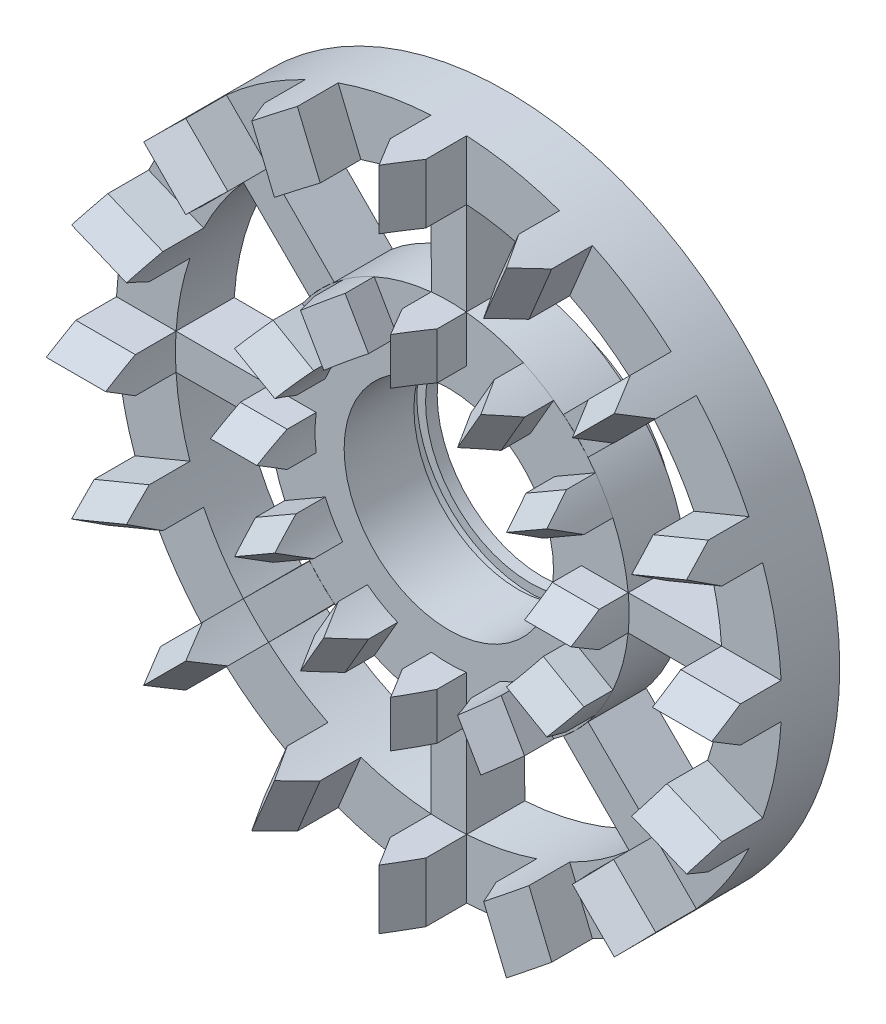
from build123d import *

# Parameters (mm, degrees)
EXTRUDE_1_DEPTH          = 6
SKETCH_4_R               = 28.608695652
SKETCH_4_R_2             = 23.5
EXTRUDE_2_DEPTH          = 5
CUT_EXTRUDE_1_DEPTH      = 6
PATTERN_CIRCULAR_1_COUNT = 16
EXTRUDE_3_DEPTH          = 5
CUT_EXTRUDE_2_DEPTH      = 5
PATTERN_CIRCULAR_7_COUNT = 12
SKETCH_8_R               = 15.48938983
SKETCH_8_R_2             = 11.5
EXTRUDE_4_DEPTH          = 5
EXTRUDE_5_DEPTH          = 5
SKETCH_10_R              = 11.5
SKETCH_10_R_2            = 9
EXTRUDE_6_DEPTH          = 8
SKETCH_11_W              = 1
SKETCH_11_H              = 0.75


with BuildPart() as part:
    # 草图1 → 凸台-拉伸1 (new body)
    with BuildSketch(Plane.XY):
        with BuildLine():
            Line((1.532608696, 23.449970375), (1.532608696, 28.567614137))
            ThreePointArc((1.532608696, 28.567614137), (0, 28.608695652), (-1.532608696, 28.567614137))
            Line((-1.532608696, 28.567614137), (-1.532608696, 23.449970375))
            ThreePointArc((-1.532608696, 23.449970375), (0, 23.5), (1.532608696, 23.449970375))
        make_face()
    extrude_1 = extrude(amount=EXTRUDE_1_DEPTH)

    # 草图4 → 凸台-拉伸2 (add)
    with BuildSketch(Plane.XY):
        Circle(SKETCH_4_R)
        Circle(SKETCH_4_R_2, mode=Mode.SUBTRACT)
    extrude(amount=-EXTRUDE_2_DEPTH)

    # 草图5 → 切除-拉伸1 (cut)
    with BuildSketch(Plane(origin=(0, 23, 0), x_dir=(1, 0, 0), z_dir=(0, 1, 0))):
        Polygon((0, -6), (-1.532608696, -3.5), (-1.532608696, -6), align=None)
        Polygon((1.532608696, -3.5), (0, -6), (1.532608696, -6), align=None)
    cut_extrude_1 = extrude(amount=CUT_EXTRUDE_1_DEPTH, mode=Mode.SUBTRACT)

    # 阵列(圆周)1: 凸台-拉伸1, 切除-拉伸1 ×16 about axis
    pattern_circular_1_axis = Axis((0, 0, 0), (0, 0, 1))
    for i in range(1, PATTERN_CIRCULAR_1_COUNT):
        add(extrude_1.rotate(pattern_circular_1_axis, i * 360 / PATTERN_CIRCULAR_1_COUNT))
        add(cut_extrude_1.rotate(pattern_circular_1_axis, i * 360 / PATTERN_CIRCULAR_1_COUNT), mode=Mode.SUBTRACT)

    # 草图9 → 凸台-拉伸5 (add)
    with BuildSketch(Plane.XY):
        with BuildLine():
            ThreePointArc((1.532608696, 23.449970375), (0, 23.5), (-1.532608696, 23.449970375))
            Line((-1.532608696, 23.449970375), (-1.500043254, 15.427244415))
            ThreePointArc((-1.500043254, 15.427244415), (-2.1729e-05, 15.5), (1.5, 15.427248621))
            Line((1.5, 15.427248621), (1.532608696, 23.449970375))
        make_face()
        with BuildLine():
            ThreePointArc((17.665351072, 15.497915069), (16.617009358, 16.617009358), (15.497915069, 17.665351072))
            Line((15.497915069, 17.665351072), (9.848018383, 11.969399898))
            ThreePointArc((9.848018383, 11.969399898), (10.960139744, 10.960170473), (11.969372286, 9.848051943))
            Line((11.969372286, 9.848051943), (17.665351072, 15.497915069))
        make_face()
        with BuildLine():
            ThreePointArc((23.449970375, -1.532608696), (23.5, 0), (23.449970375, 1.532608696))
            Line((23.449970375, 1.532608696), (15.427244415, 1.500043254))
            ThreePointArc((15.427244415, 1.500043254), (15.5, 2.1729e-05), (15.427248621, -1.5))
            Line((15.427248621, -1.5), (23.449970375, -1.532608696))
        make_face()
        with BuildLine():
            ThreePointArc((15.497915069, -17.665351072), (16.617009358, -16.617009358), (17.665351072, -15.497915069))
            Line((17.665351072, -15.497915069), (11.969399898, -9.848018383))
            ThreePointArc((11.969399898, -9.848018383), (10.960170473, -10.960139744), (9.848051943, -11.969372286))
            Line((9.848051943, -11.969372286), (15.497915069, -17.665351072))
        make_face()
        with BuildLine():
            ThreePointArc((-1.532608696, -23.449970375), (0, -23.5), (1.532608696, -23.449970375))
            Line((1.532608696, -23.449970375), (1.500043254, -15.427244415))
            ThreePointArc((1.500043254, -15.427244415), (2.1729e-05, -15.5), (-1.5, -15.427248621))
            Line((-1.5, -15.427248621), (-1.532608696, -23.449970375))
        make_face()
        with BuildLine():
            ThreePointArc((-17.665351072, -15.497915069), (-16.617009358, -16.617009358), (-15.497915069, -17.665351072))
            Line((-15.497915069, -17.665351072), (-9.848018383, -11.969399898))
            ThreePointArc((-9.848018383, -11.969399898), (-10.960139744, -10.960170473), (-11.969372286, -9.848051943))
            Line((-11.969372286, -9.848051943), (-17.665351072, -15.497915069))
        make_face()
        with BuildLine():
            ThreePointArc((-23.449970375, 1.532608696), (-23.5, 0), (-23.449970375, -1.532608696))
            Line((-23.449970375, -1.532608696), (-15.427244415, -1.500043254))
            ThreePointArc((-15.427244415, -1.500043254), (-15.5, -2.1729e-05), (-15.427248621, 1.5))
            Line((-15.427248621, 1.5), (-23.449970375, 1.532608696))
        make_face()
        with BuildLine():
            ThreePointArc((-15.497915069, 17.665351072), (-16.617009358, 16.617009358), (-17.665351072, 15.497915069))
            Line((-17.665351072, 15.497915069), (-11.969399898, 9.848018383))
            ThreePointArc((-11.969399898, 9.848018383), (-10.960170473, 10.960139744), (-9.848051943, 11.969372286))
            Line((-9.848051943, 11.969372286), (-15.497915069, 17.665351072))
        make_face()
    extrude(amount=-EXTRUDE_5_DEPTH)


with BuildPart() as body_2:
    # 草图6 → 凸台-拉伸3 (new body)
    with BuildSketch(Plane.XY):
        with BuildLine():
            Line((1.5, 11.401754251), (1.5, 15.427248621))
            ThreePointArc((1.5, 15.427248621), (0, 15.5), (-1.5, 15.427248621))
            Line((-1.5, 15.427248621), (-1.5, 11.401754251))
            ThreePointArc((-1.5, 11.401754251), (0, 11.5), (1.5, 11.401754251))
        make_face()
    extrude(amount=EXTRUDE_3_DEPTH)

    # 草图7 → 切除-拉伸2 (cut)
    with BuildSketch(Plane(origin=(0, 11, 0), x_dir=(1, 0, 0), z_dir=(0, 1, 0))):
        Polygon((-1.5, -2.5), (-1.5, -5), (0, -5), align=None)
        Polygon((1.5, -2.5), (0, -5), (1.5, -5), align=None)
    extrude(amount=CUT_EXTRUDE_2_DEPTH, mode=Mode.SUBTRACT)


with BuildPart() as pattern_circular_7_1:
    # 阵列(圆周)7: pattern copy
    add(body_2.part.rotate(Axis((0, 0, 0), (0, 0, 1)), 1 * 360 / PATTERN_CIRCULAR_7_COUNT))


with BuildPart() as pattern_circular_7_2:
    # 阵列(圆周)7: pattern copy
    add(body_2.part.rotate(Axis((0, 0, 0), (0, 0, 1)), 2 * 360 / PATTERN_CIRCULAR_7_COUNT))


with BuildPart() as pattern_circular_7_3:
    # 阵列(圆周)7: pattern copy
    add(body_2.part.rotate(Axis((0, 0, 0), (0, 0, 1)), 3 * 360 / PATTERN_CIRCULAR_7_COUNT))


with BuildPart() as pattern_circular_7_4:
    # 阵列(圆周)7: pattern copy
    add(body_2.part.rotate(Axis((0, 0, 0), (0, 0, 1)), 4 * 360 / PATTERN_CIRCULAR_7_COUNT))


with BuildPart() as pattern_circular_7_5:
    # 阵列(圆周)7: pattern copy
    add(body_2.part.rotate(Axis((0, 0, 0), (0, 0, 1)), 5 * 360 / PATTERN_CIRCULAR_7_COUNT))


with BuildPart() as pattern_circular_7_6:
    # 阵列(圆周)7: pattern copy
    add(body_2.part.rotate(Axis((0, 0, 0), (0, 0, 1)), 6 * 360 / PATTERN_CIRCULAR_7_COUNT))


with BuildPart() as pattern_circular_7_7:
    # 阵列(圆周)7: pattern copy
    add(body_2.part.rotate(Axis((0, 0, 0), (0, 0, 1)), 7 * 360 / PATTERN_CIRCULAR_7_COUNT))


with BuildPart() as pattern_circular_7_8:
    # 阵列(圆周)7: pattern copy
    add(body_2.part.rotate(Axis((0, 0, 0), (0, 0, 1)), 8 * 360 / PATTERN_CIRCULAR_7_COUNT))


with BuildPart() as pattern_circular_7_9:
    # 阵列(圆周)7: pattern copy
    add(body_2.part.rotate(Axis((0, 0, 0), (0, 0, 1)), 9 * 360 / PATTERN_CIRCULAR_7_COUNT))


with BuildPart() as pattern_circular_7_10:
    # 阵列(圆周)7: pattern copy
    add(body_2.part.rotate(Axis((0, 0, 0), (0, 0, 1)), 10 * 360 / PATTERN_CIRCULAR_7_COUNT))


with BuildPart() as pattern_circular_7_11:
    # 阵列(圆周)7: pattern copy
    add(body_2.part.rotate(Axis((0, 0, 0), (0, 0, 1)), 11 * 360 / PATTERN_CIRCULAR_7_COUNT))


with BuildPart() as body_2_1:
    add(body_2.part)

    add(pattern_circular_7_1.part)  # 凸台-拉伸4 merges 阵列(圆周)7_1

    add(pattern_circular_7_2.part)  # 凸台-拉伸4 merges 阵列(圆周)7_2

    add(pattern_circular_7_3.part)  # 凸台-拉伸4 merges 阵列(圆周)7_3

    add(pattern_circular_7_4.part)  # 凸台-拉伸4 merges 阵列(圆周)7_4

    add(pattern_circular_7_5.part)  # 凸台-拉伸4 merges 阵列(圆周)7_5

    add(pattern_circular_7_6.part)  # 凸台-拉伸4 merges 阵列(圆周)7_6

    add(pattern_circular_7_7.part)  # 凸台-拉伸4 merges 阵列(圆周)7_7

    add(pattern_circular_7_8.part)  # 凸台-拉伸4 merges 阵列(圆周)7_8

    add(pattern_circular_7_9.part)  # 凸台-拉伸4 merges 阵列(圆周)7_9

    add(pattern_circular_7_10.part)  # 凸台-拉伸4 merges 阵列(圆周)7_10

    add(pattern_circular_7_11.part)  # 凸台-拉伸4 merges 阵列(圆周)7_11
    # 草图8 → 凸台-拉伸4 (add)
    with BuildSketch(Plane.XY):
        Circle(SKETCH_8_R)
        Circle(SKETCH_8_R_2, mode=Mode.SUBTRACT)
    extrude(amount=-EXTRUDE_4_DEPTH)

    # 草图10 → 凸台-拉伸6 (add)
    with BuildSketch(Plane.XY):
        Circle(SKETCH_10_R)
        Circle(SKETCH_10_R_2, mode=Mode.SUBTRACT)
    extrude(amount=-EXTRUDE_6_DEPTH)

    # 草图11 → 切除-旋转1 (revolve, cut)
    with BuildSketch(Plane(origin=(0, 0, 0), x_dir=(0, 0, -1), z_dir=(1, 0, 0))):
        with Locations((6.5, 9.375)):
            Rectangle(SKETCH_11_W, SKETCH_11_H)
    revolve(axis=Axis((0, 0, -8), (0, 0, 1)), mode=Mode.SUBTRACT)


solid = Compound([part.part, body_2_1.part])
